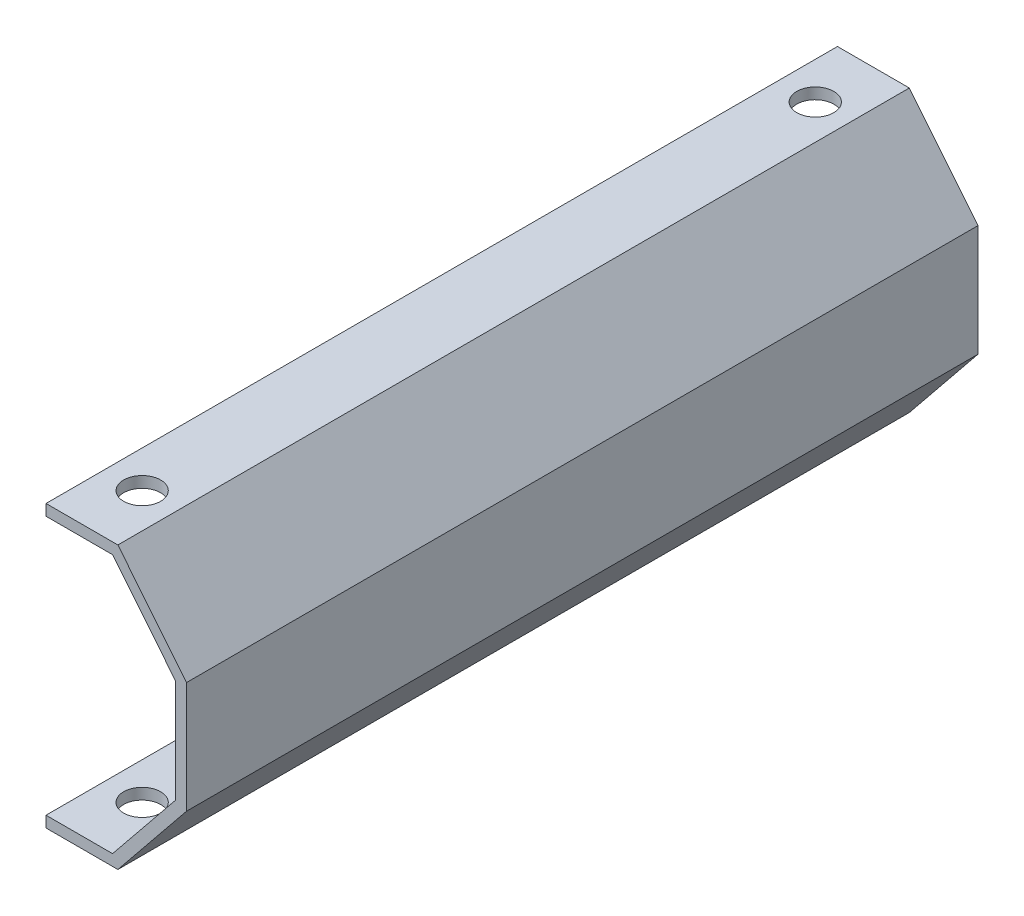
from build123d import *

# Parameters (mm, degrees)
SALIENTE_EXTRUIR1_DEPTH = 107
CORTAR_EXTRUIR1_REACH   = 40
CROQUIS3_R              = 2.5
CORTAR_EXTRUIR2_REACH   = 40
CROQUIS4_R              = 2.5


with BuildPart() as part:
    # Croquis1 → Saliente-Extruir1 (new body)
    with BuildSketch(Plane.XY):
        Polygon((0, 0), (9, 0), (17.5, 10.5), (17.5, 24.5), (9, 35), (0, 35), (0, 36.5), (9.715608012, 36.5), (19, 25.031045192), (19, 9.968954808), (9.715608012, -1.5), (0, -1.5), align=None)
    extrude(amount=SALIENTE_EXTRUIR1_DEPTH)

    # Croquis3 → Cortar-Extruir1 (cut, up to next)
    with BuildSketch(Plane(origin=(0, 36.5, 0), x_dir=(1, 0, 0), z_dir=(0, 1, 0)), mode=Mode.PRIVATE) as cortar_extruir1_sk1:
        with Locations((5, -8)):
            Circle(CROQUIS3_R)
    cortar_extruir1_tool1 = extrude(cortar_extruir1_sk1.sketch, amount=-CORTAR_EXTRUIR1_REACH, mode=Mode.PRIVATE) & part.part
    add(cortar_extruir1_tool1.solids().sort_by_distance((5, 36.5, 8))[0], mode=Mode.SUBTRACT)
    # Croquis3 → Cortar-Extruir1 (cut, up to next)
    with BuildSketch(Plane(origin=(0, 36.5, 0), x_dir=(1, 0, 0), z_dir=(0, 1, 0)), mode=Mode.PRIVATE) as cortar_extruir1_sk2:
        with Locations((5, -99)):
            Circle(CROQUIS3_R)
    cortar_extruir1_tool2 = extrude(cortar_extruir1_sk2.sketch, amount=-CORTAR_EXTRUIR1_REACH, mode=Mode.PRIVATE) & part.part
    add(cortar_extruir1_tool2.solids().sort_by_distance((5, 36.5, 99))[0], mode=Mode.SUBTRACT)

    # Croquis4 → Cortar-Extruir2 (cut, up to next)
    with BuildSketch(Plane.XZ.offset(1.5), mode=Mode.PRIVATE) as cortar_extruir2_sk1:
        with Locations((5, 8)):
            Circle(CROQUIS4_R)
    cortar_extruir2_tool1 = extrude(cortar_extruir2_sk1.sketch, amount=-CORTAR_EXTRUIR2_REACH, mode=Mode.PRIVATE) & part.part
    add(cortar_extruir2_tool1.solids().sort_by_distance((5, -1.5, 8))[0], mode=Mode.SUBTRACT)
    # Croquis4 → Cortar-Extruir2 (cut, up to next)
    with BuildSketch(Plane.XZ.offset(1.5), mode=Mode.PRIVATE) as cortar_extruir2_sk2:
        with Locations((5, 99)):
            Circle(CROQUIS4_R)
    cortar_extruir2_tool2 = extrude(cortar_extruir2_sk2.sketch, amount=-CORTAR_EXTRUIR2_REACH, mode=Mode.PRIVATE) & part.part
    add(cortar_extruir2_tool2.solids().sort_by_distance((5, -1.5, 99))[0], mode=Mode.SUBTRACT)


solid = part.part
